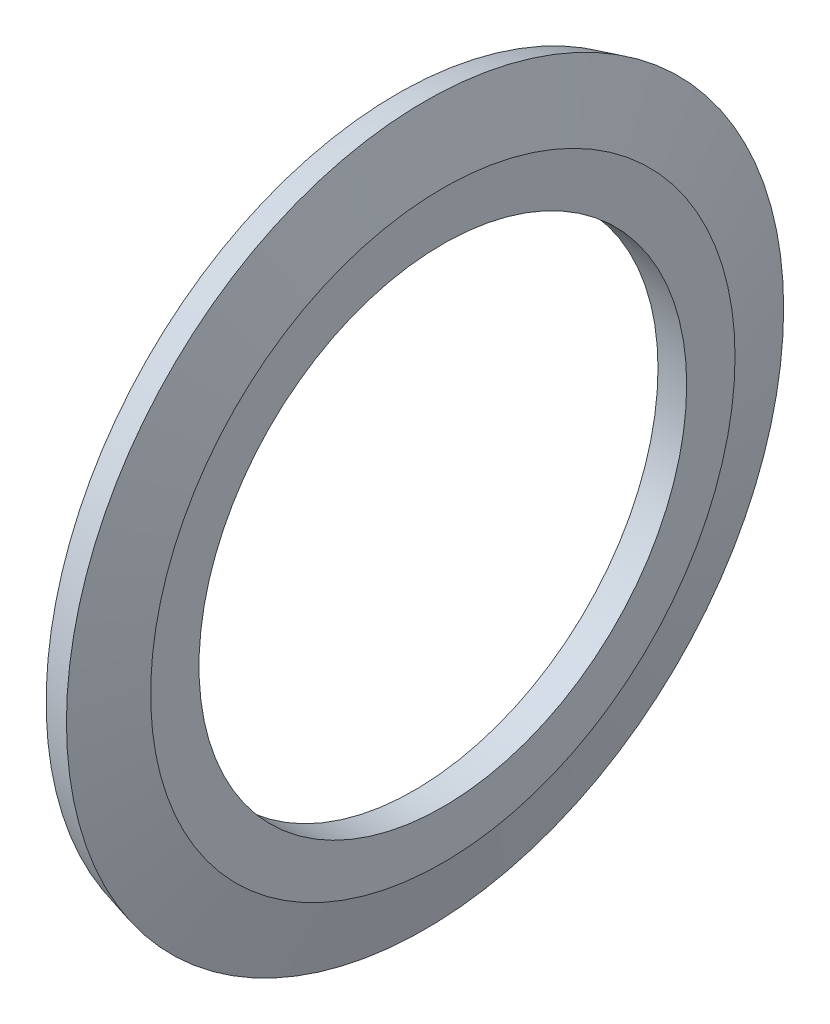
from build123d import *


with BuildPart() as part:
    # Sketch1 → Revolve1 (revolve)
    with BuildSketch(Plane.XY):
        Polygon((1, 8.5), (0, 8.5), (0, 10.053347502), (-0.586228207, 12.241180955), (0.37969762, 12.5), (1, 10.185), align=None)
    revolve(axis=Axis((1, 0, 0), (-1, 0, 0)))


solid = part.part
